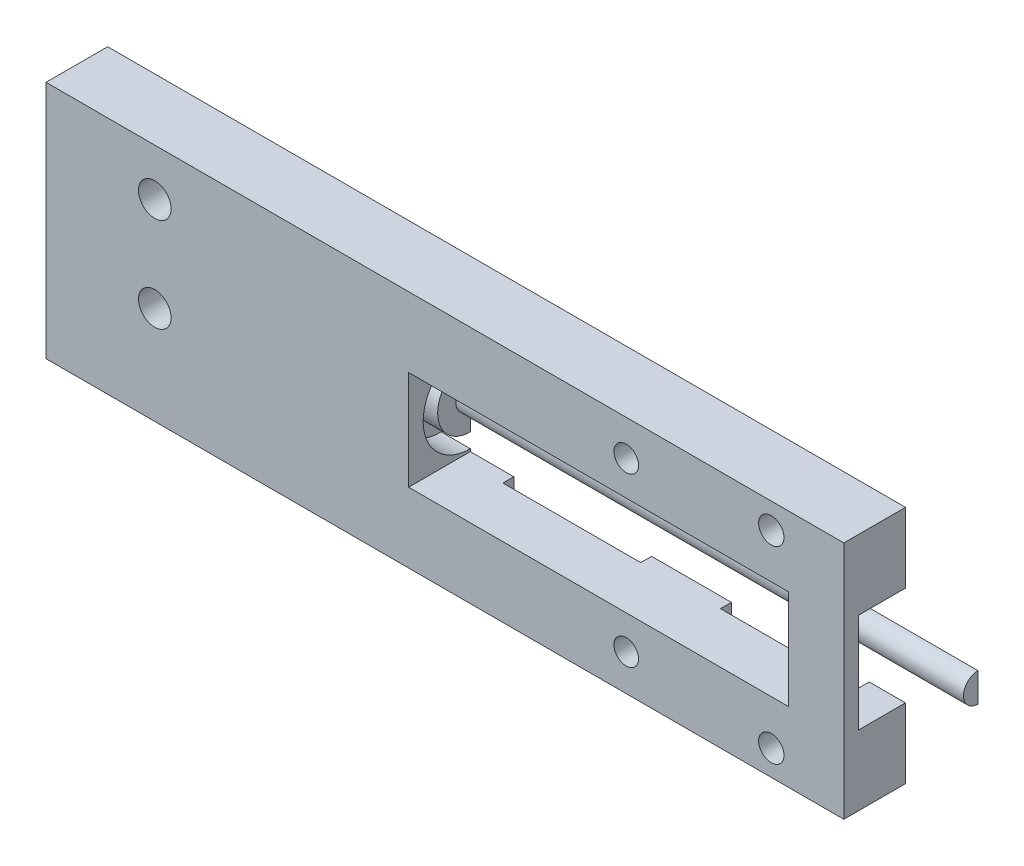
from build123d import *

# Parameters (mm, degrees)
RESSALTO_EXTRUS_O1_DEPTH        = 8.5
ESBO_O8_W                       = 19
ESBO_O8_H                       = 1.5
CORTE_EXTRUS_O1_DEPTH           = 3
ESBO_O5_W                       = 19
ESBO_O5_H                       = 1.5
CORTE_EXTRUS_O2_DEPTH           = 3
ESBO_O11_R                      = 2.25
CORTE_EXTRUS_O6_DEPTH           = 83.124904871
ESBO_O12_R                      = 2.25
CORTE_EXTRUS_O7_DEPTH           = 116.157500841
ESBO_O15_R                      = 6.5
CORTE_EXTRUS_O12_DEPTH          = 4
RESSALTO_EXTRUS_O2_DEPTH        = 4
ESBO_O17_R                      = 1.8
ESBO_O17_R_2                    = 1.7
CORTE_EXTRUS_O13_DEPTH          = 1.6
ESBO_O8_4_W                     = 19
ESBO_O8_4_H                     = 1.5
CORTE_EXTRUS_O14_DEPTH          = 3
ESBO_O11_7_R                    = 1.7
CORTE_EXTRUS_O18_DEPTH          = 83.124904871
RESSALTO_EXTRUS_O3_DEPTH        = 70
SKIZZE1_W                       = 7.6
SKIZZE1_H                       = 2
AUFSATZ_LINEAR_AUSTRAGEN1_DEPTH = 15
SKETCH1_R                       = 1.75
CUT_EXTRUDE1_DEPTH              = 10


with BuildPart() as part:
    # Esboço4 → Ressalto-extrusão1 (new body)
    with BuildSketch(Plane.XY):
        Polygon((-80, 16.5), (30, 16.5), (30, 6.85), (-30, 6.85), (-30, -6.85), (30, -6.85), (30, -16.5), (-80, -16.5), align=None)
    extrude(amount=RESSALTO_EXTRUS_O1_DEPTH)

    # Esboço8 → Corte-extrusão1 (cut)
    with BuildSketch(Plane(origin=(-30, -6.85, 8.5), x_dir=(1, 0, 0), z_dir=(0, 1, 0))):
        with Locations((15.5, 7.75)):
            Rectangle(ESBO_O8_W, ESBO_O8_H)
    extrude(amount=-CORTE_EXTRUS_O1_DEPTH, mode=Mode.SUBTRACT)

    # Esboço5 → Corte-extrusão2 (cut)
    with BuildSketch(Plane(origin=(-30, 6.85, 8.5), x_dir=(1, 0, 0), z_dir=(0, 1, 0))):
        with Locations((15.5, 7.75)):
            Rectangle(ESBO_O5_W, ESBO_O5_H)
        with Locations((45.5, 7.75)):
            Rectangle(ESBO_O5_W, ESBO_O5_H)
    extrude(amount=CORTE_EXTRUS_O2_DEPTH, mode=Mode.SUBTRACT)

    # Esboço11 → Corte-extrusão6 (cut, through all)
    with BuildSketch(Plane.XY.offset(8.5)):
        with Locations((-65, 10)):
            Circle(ESBO_O11_R)
    extrude(amount=-CORTE_EXTRUS_O6_DEPTH, mode=Mode.SUBTRACT)

    # Esboço12 → Corte-extrusão7 (cut, through all)
    with BuildSketch(Plane(origin=(-80, 16.5, 8.5), x_dir=(-1, 0, 0), z_dir=(0, 0, -1))):
        with Locations((-15, -19.5)):
            Circle(ESBO_O12_R)
    extrude(amount=CORTE_EXTRUS_O7_DEPTH, mode=Mode.SUBTRACT)

    # Esboço15 → Corte-extrusão12 (cut)
    with BuildSketch(Plane(origin=(-30, -6.85, 0), x_dir=(0, 0, 1), z_dir=(-1, 0, 0))):
        with Locations((0, 6.85)):
            Circle(ESBO_O15_R)
    extrude(amount=CORTE_EXTRUS_O12_DEPTH, mode=Mode.SUBTRACT)

    # Esboço16 → Ressalto-extrusão2 (add)
    with BuildSketch(Plane(origin=(-34, -6.5, 0), x_dir=(0, 0, -1), z_dir=(1, 0, 0))):
        with BuildLine():
            Line((0, 2), (0, 11))
            ThreePointArc((0, 11), (-4.5, 6.5), (0, 2))
        make_face()
    extrude(amount=RESSALTO_EXTRUS_O2_DEPTH)

    # Esboço17 → Corte-extrusão13 (cut)
    with BuildSketch(Plane(origin=(-80, 16.5, 0), x_dir=(-1, 0, 0), z_dir=(0, 0, -1))):
        with Locations((-5, -3)):
            Circle(ESBO_O17_R)
        with Locations((-5, -26)):
            Circle(ESBO_O17_R)
        with Locations((-52, -26)):
            Circle(ESBO_O17_R)
        with Locations((-52, -3)):
            Circle(ESBO_O17_R)
        with Locations((-107, -26)):
            Circle(ESBO_O17_R_2)
        with Locations((-107, -3)):
            Circle(ESBO_O17_R)
    extrude(amount=-CORTE_EXTRUS_O13_DEPTH, mode=Mode.SUBTRACT)

    # Esboço8<4> → Corte-extrusão14 (cut)
    with BuildSketch(Plane(origin=(-30, -6.85, 8.5), x_dir=(1, 0, 0), z_dir=(0, 1, 0))):
        with Locations((15.5, 7.75)):
            Rectangle(ESBO_O8_4_W, ESBO_O8_4_H)
        with Locations((45.5, 7.75)):
            Rectangle(ESBO_O8_4_W, ESBO_O8_4_H)
    extrude(amount=-CORTE_EXTRUS_O14_DEPTH, mode=Mode.SUBTRACT)

    # Esboço11<7> → Corte-extrusão18 (cut, through all)
    with BuildSketch(Plane.XY.offset(8.5)):
        with Locations((0, 11.6)):
            Circle(ESBO_O11_7_R)
        with Locations((0, -11.5)):
            Circle(ESBO_O11_7_R)
    extrude(amount=-CORTE_EXTRUS_O18_DEPTH, mode=Mode.SUBTRACT)

    # Esboço18 → Ressalto-extrusão3 (add)
    with BuildSketch(Plane(origin=(-30, -4.5, 0), x_dir=(0, 0, 1), z_dir=(-1, 0, 0))):
        with BuildLine():
            Line((0, 2.5), (0, 6.5))
            ThreePointArc((0, 6.5), (2, 4.5), (0, 2.5))
        make_face()
    extrude(amount=-RESSALTO_EXTRUS_O3_DEPTH)

    # Skizze1 → Aufsatz-Linear austragen1 (add)
    with BuildSketch(Plane(origin=(0, -6.85, 0), x_dir=(1, 0, 0), z_dir=(0, 1, 0))):
        with Locations((26.2, -7.5)):
            Rectangle(SKIZZE1_W, SKIZZE1_H)
    extrude(amount=AUFSATZ_LINEAR_AUSTRAGEN1_DEPTH)

    # Sketch1 → Cut-Extrude1 (cut)
    with BuildSketch(Plane.XY.offset(8.5)):
        with Locations((20, 13)):
            Circle(SKETCH1_R)
        with Locations((20, -13)):
            Circle(SKETCH1_R)
    extrude(amount=-CUT_EXTRUDE1_DEPTH, mode=Mode.SUBTRACT)


solid = part.part
